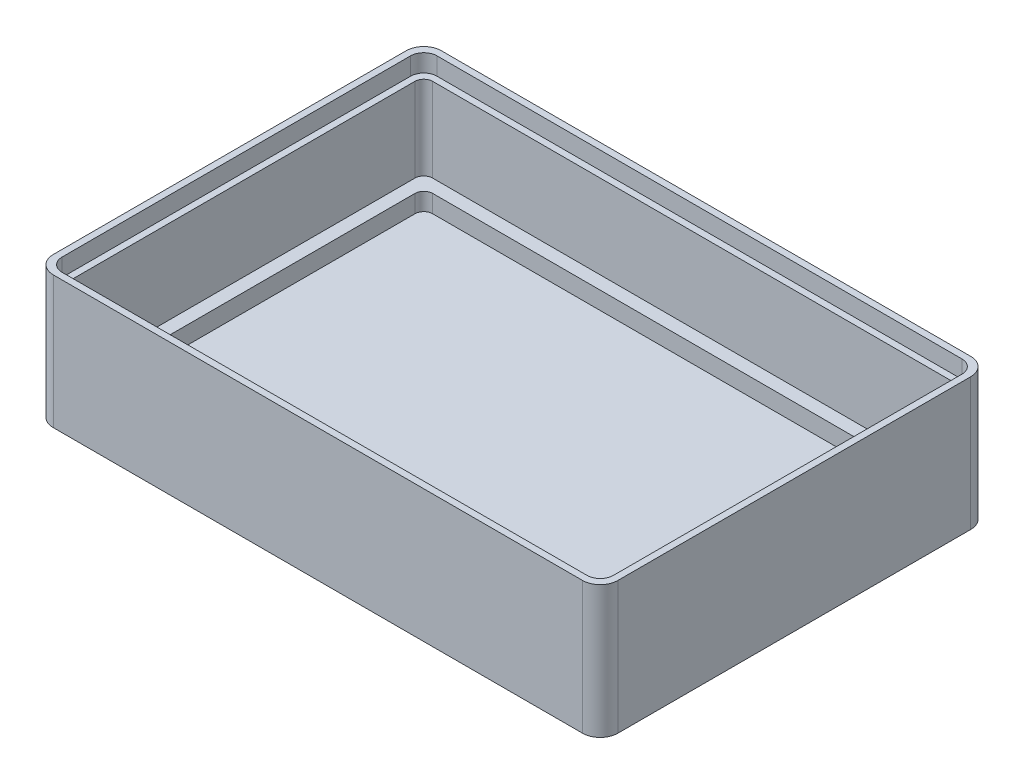
from build123d import *

# Parameters (mm, degrees)
SKETCH1_W           = 64
SKETCH1_H           = 44
BOSS_EXTRUDE1_DEPTH = 15
SKETCH2_W           = 61
SKETCH2_H           = 41
CUT_EXTRUDE1_DEPTH  = 13.5
SKETCH3_W           = 61
SKETCH3_H           = 41
SKETCH3_W_2         = 58
SKETCH3_H_2         = 38
BOSS_EXTRUDE2_DEPTH = 2
FILLET1_R           = 1
FILLET2_R           = 2
CUT_EXTRUDE2_DEPTH  = 2


with BuildPart() as part:
    # Sketch1 → Boss-Extrude1 (new body)
    with BuildSketch(Plane(origin=(0, 0, 0), x_dir=(1, 0, 0), z_dir=(0, 1, 0))):
        with Locations((32, 22)):
            Rectangle(SKETCH1_W, SKETCH1_H)
    extrude(amount=BOSS_EXTRUDE1_DEPTH)

    # Sketch2 → Cut-Extrude1 (cut)
    with BuildSketch(Plane(origin=(0, 15, 0), x_dir=(1, 0, 0), z_dir=(0, 1, 0))):
        with Locations((32, 22)):
            Rectangle(SKETCH2_W, SKETCH2_H)
    extrude(amount=-CUT_EXTRUDE1_DEPTH, mode=Mode.SUBTRACT)

    # Sketch3 → Boss-Extrude2 (add)
    with BuildSketch(Plane(origin=(0, 1.5, 0), x_dir=(1, 0, 0), z_dir=(0, 1, 0))):
        with Locations((32, 22)):
            Rectangle(SKETCH3_W, SKETCH3_H)
        with Locations((32.004099557, 22)):
            Rectangle(SKETCH3_W_2, SKETCH3_H_2, mode=Mode.SUBTRACT)
    extrude(amount=BOSS_EXTRUDE2_DEPTH)

    # Fillet1
    fillet1_edges = [part.edges().sort_by_distance(p)[0] for p in [
        (1.5, 9.25, -42.5),
        (62.5, 9.25, -42.5),
        (1.5, 9.25, -1.5),
        (62.5, 9.25, -1.5),
        (61.004099557, 2.5, -41),
        (3.004099557, 2.5, -41),
        (3.004099557, 2.5, -3),
        (61.004099557, 2.5, -3),
    ]]
    fillet(fillet1_edges, radius=FILLET1_R)

    # Fillet2
    fillet2_edges = [part.edges().sort_by_distance(p)[0] for p in [
        (0, 7.5, -44),
        (64, 7.5, -44),
        (64, 7.5, 0),
        (0, 7.5, 0),
    ]]
    fillet(fillet2_edges, radius=FILLET2_R)

    # Sketch4 → Cut-Extrude2 (cut)
    with BuildSketch(Plane(origin=(0, 15, 0), x_dir=(1, 0, 0), z_dir=(0, 1, 0))):
        with BuildLine():
            Line((2.25, 43.25), (61.75, 43.25))
            ThreePointArc((61.75, 43.25), (62.810660172, 42.810660172), (63.25, 41.75))
            Line((63.25, 41.75), (63.25, 2.25))
            ThreePointArc((63.25, 2.25), (62.810660172, 1.189339828), (61.75, 0.75))
            Line((61.75, 0.75), (2.25, 0.75))
            ThreePointArc((2.25, 0.75), (1.189339828, 1.189339828), (0.75, 2.25))
            Line((0.75, 2.25), (0.75, 41.75))
            ThreePointArc((0.75, 41.75), (1.189339828, 42.810660172), (2.25, 43.25))
        make_face()
        with BuildLine():
            Line((61.5, 42.5), (2.5, 42.5))
            ThreePointArc((2.5, 42.5), (1.792893219, 42.207106781), (1.5, 41.5))
            Line((1.5, 41.5), (1.5, 2.5))
            ThreePointArc((1.5, 2.5), (1.792893219, 1.792893219), (2.5, 1.5))
            Line((2.5, 1.5), (61.5, 1.5))
            ThreePointArc((61.5, 1.5), (62.207106781, 1.792893219), (62.5, 2.5))
            Line((62.5, 2.5), (62.5, 41.5))
            ThreePointArc((62.5, 41.5), (62.207106781, 42.207106781), (61.5, 42.5))
        make_face(mode=Mode.SUBTRACT)
    extrude(amount=-CUT_EXTRUDE2_DEPTH, mode=Mode.SUBTRACT)


solid = part.part
